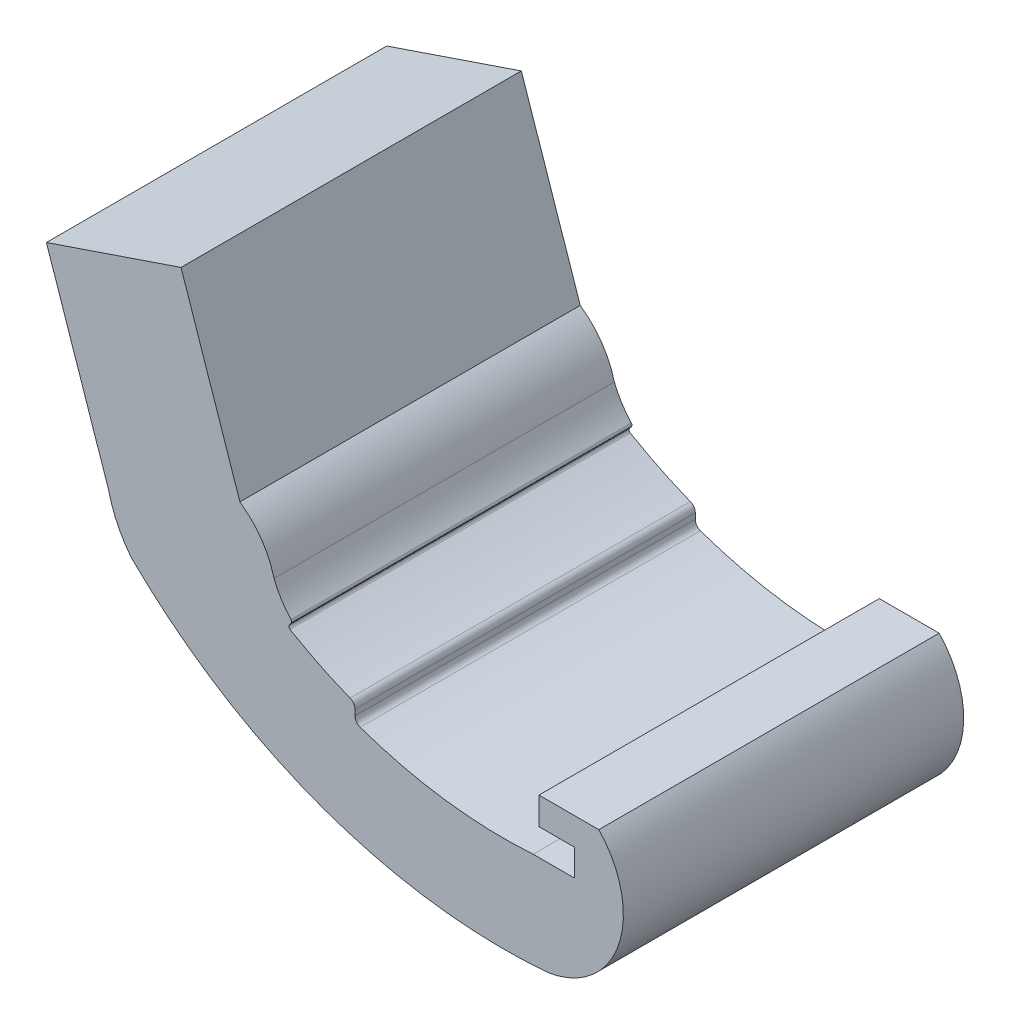
from build123d import *

# Parameters (mm, degrees)
BOSS_EXTRUDE1_DEPTH = 17.4625


with BuildPart() as part:
    # Sketch1 → Boss-Extrude1 (new body)
    with BuildSketch(Plane.XY):
        with BuildLine():
            Line((17.165632348, -15.146713758), (19.25021974, -15.146713758))
            ThreePointArc((19.25021974, -15.146713758), (19.268180252, -15.139274271), (19.27561974, -15.121313758))
            Line((19.27561974, -15.121313758), (19.27561974, -13.771938758))
            Line((19.27561974, -13.771938758), (17.462436286, -13.771938758))
            Line((17.462436286, -13.771938758), (17.462436286, -12.368588758))
            Line((17.462436286, -12.368588758), (20.535179361, -12.368588758))
            ThreePointArc((20.535179361, -12.368588758), (21.54921714, -16.988767417), (17.921869262, -20.024664455))
            ThreePointArc((17.921869262, -20.024664455), (6.385080471, -18.490906221), (-3.456137762, -12.277989546))
            ThreePointArc((-3.456137762, -12.277989546), (-4.173487151, -11.127601987), (-4.620530274, -9.847705847))
            Line((-4.620530274, -9.847705847), (-7.811999534, -0.450394448))
            Line((-7.811999534, -0.450394448), (-0.904044887, 1.896214799))
            Line((-0.904044887, 1.896214799), (2.118621316, -7.011726883))
            ThreePointArc((2.118621316, -7.011726883), (3.222227995, -8.118323003), (3.87016333, -9.540533423))
            ThreePointArc((3.87016333, -9.540533423), (4.239027768, -10.27403939), (4.736122073, -10.927483519))
            ThreePointArc((4.736122073, -10.927483519), (4.769468956, -11.008731963), (4.742121249, -11.092191097))
            Line((4.742121249, -11.092191097), (4.651650579, -11.206452905))
            ThreePointArc((4.651650579, -11.206452905), (4.626334833, -11.308376501), (4.686416978, -11.394512685))
            ThreePointArc((4.686416978, -11.394512685), (6.198075477, -12.211534349), (7.770150037, -12.905232694))
            ThreePointArc((7.770150037, -12.905232694), (7.952657914, -13.051135413), (8.021441195, -13.274441457))
            Line((8.021441195, -13.274441457), (8.021441195, -13.569821942))
            ThreePointArc((8.021441195, -13.569821942), (8.094604206, -13.799430989), (8.287118368, -13.944384215))
            ThreePointArc((8.287118368, -13.944384215), (12.665355124, -14.99614841), (17.165632348, -15.146713758))
        make_face()
    extrude(amount=BOSS_EXTRUDE1_DEPTH)


solid = part.part
